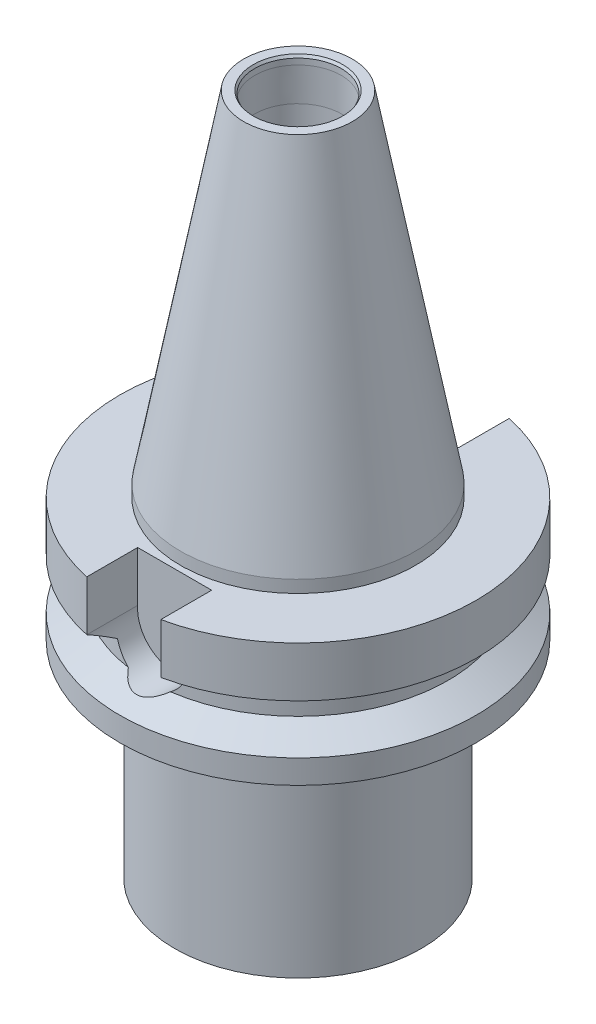
from build123d import *

# Parameters (mm, degrees)
CUT_EXTRUDE_1_DEPTH = 20


with BuildPart() as part:
    # 草图1 → 旋转2 (revolve)
    with BuildSketch(Plane.XY):
        Polygon((-10.868417819, 98.635802469), (-13.209567901, 98.635802469), (-28.575, 15.835802469), (-28.575, 12.835802469), (-43.313271605, 12.835802469), (-43.313271605, 0.635802469), (-36.5, -3.297841726), (-36.5, -7.430553336), (-43.313271605, -11.364197531), (-43.313271605, -17.164197531), (-30, -17.164197531), (-30, -67.164197531), (-20.5, -67.164197531), (-16, -31.164197531), (0, -31.164197531), (0, 25.628046603), (-9.486874299, 31.105296033), (-9.486874299, 45.695475602), (-10.727694805, 46.411863655), (-10.727694805, 88.230958782), (-10.5, 96.54970542), (-10.5, 97.997684089), align=None)
    revolve(axis=Axis((0, 104.892592593, 0), (0, -1, 0)))

    # 草图3 → 切除-拉伸1 (cut)
    with BuildSketch(Plane.XY.offset(50)):
        with BuildLine():
            Line((-9, 12.835802469), (-9, 0.635802469))
            ThreePointArc((-9, 0.635802469), (0, -9.022430093), (9, 0.635802469))
            Line((9, 0.635802469), (9, 12.835802469))
            Line((9, 12.835802469), (-9, 12.835802469))
        make_face()
    cut_extrude_1 = extrude(amount=-CUT_EXTRUDE_1_DEPTH, mode=Mode.SUBTRACT)

    # 镜向1: 切除-拉伸1 across plane
    add(cut_extrude_1.mirror(Plane.XY), mode=Mode.SUBTRACT)


solid = part.part
